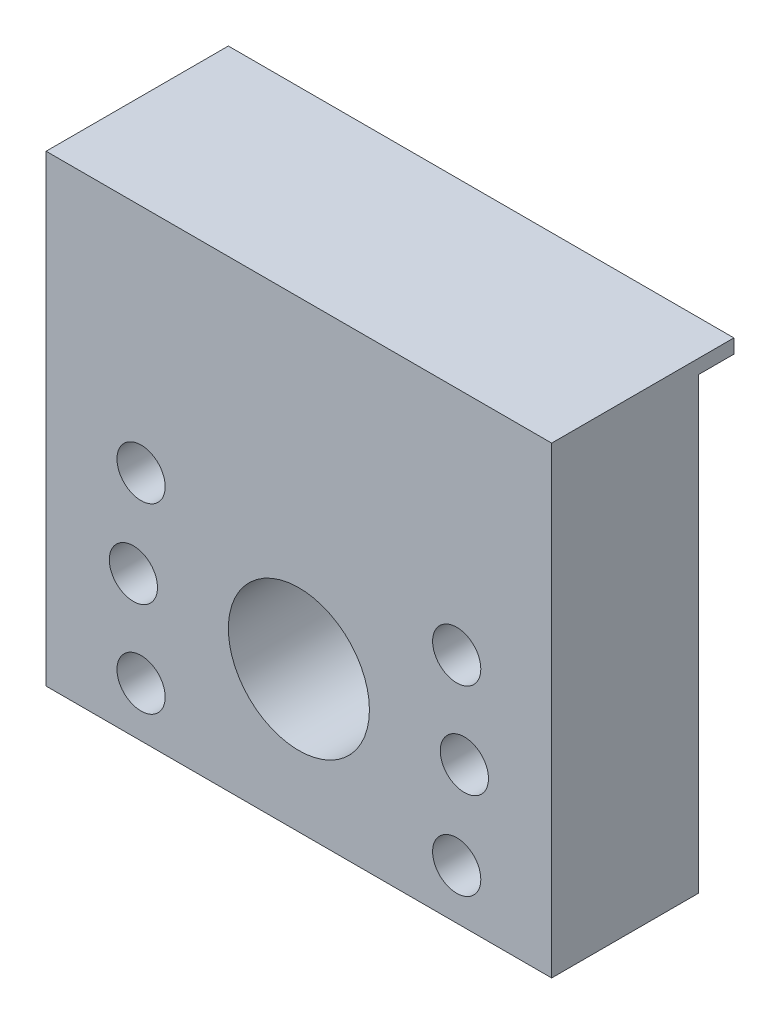
from build123d import *

# Parameters (mm, degrees)
SKETCH1_W             = 43
SKETCH1_H             = 48.1
SKETCH1_R             = 2.05
SKETCH1_R_2           = 6
BOSS_EXTRUDE1_DEPTH   = 12.5
SKETCH1_3_W           = 43
SKETCH1_3_H           = 10
BOSS_EXTRUDE2_DEPTH   = 3
MOVE_FACE1_BY         = 0.1
CROQUIS1_W            = 43
CROQUIS1_H            = 8.7
CORTAR_EXTRUIR1_DEPTH = 230.388992761
CROQUIS2_R            = 1.6
PINES_PRE_SERIE_DEPTH = 3
CROQUIS3_R            = 2.05
CORTAR_EXTRUIR2_DEPTH = 230.205824533


with BuildPart() as part:
    # Sketch1 → Boss-Extrude1 (new body)
    with BuildSketch(Plane.XY):
        with Locations((204, -15.05)):
            Rectangle(SKETCH1_W, SKETCH1_H)
        with Locations((217.423393759, -19.35)):
            Circle(SKETCH1_R, mode=Mode.SUBTRACT)
        with Locations((190.576606241, -34.85)):
            Circle(SKETCH1_R, mode=Mode.SUBTRACT)
        with Locations((217.423393759, -34.85)):
            Circle(SKETCH1_R, mode=Mode.SUBTRACT)
        with Locations((190.576606241, -19.35)):
            Circle(SKETCH1_R, mode=Mode.SUBTRACT)
        with Locations((204, -27.1)):
            Circle(SKETCH1_R_2, mode=Mode.SUBTRACT)
    extrude(amount=BOSS_EXTRUDE1_DEPTH)

    # Sketch1_3 → Boss-Extrude2 (add)
    with BuildSketch(Plane.XY):
        with Locations((204, 4)):
            Rectangle(SKETCH1_3_W, SKETCH1_3_H)
    extrude(amount=-BOSS_EXTRUDE2_DEPTH)

    # Move Face1: a face moved inward by 0.1
    extrude(part.faces().sort_by_distance((204, -1, -1.5))[0], amount=MOVE_FACE1_BY, dir=(0, 1, 0), mode=Mode.SUBTRACT)

    # Croquis1 → Cortar-Extruir1 (cut, through all)
    with BuildSketch(Plane(origin=(0, 0, -3), x_dir=(-1, 0, 0), z_dir=(0, 0, -1))):
        with Locations((-204, 4.65)):
            Rectangle(CROQUIS1_W, CROQUIS1_H)
    extrude(amount=-CORTAR_EXTRUIR1_DEPTH, mode=Mode.SUBTRACT)

    # Croquis2 → Pines Pre-serie (add)
    with BuildSketch(Plane(origin=(0, 0, 0), x_dir=(-1, 0, 0), z_dir=(0, 0, -1))):
        with Locations(Location((-210.9715045, -32.275, 0), (0, 0, 180))):
            Circle(CROQUIS2_R)
        with Locations(Location((-197.0284955, -32.275, 0), (0, 0, 180))):
            Circle(CROQUIS2_R)
    extrude(amount=PINES_PRE_SERIE_DEPTH)

    # Croquis3 → Cortar-Extruir2 (cut, through all)
    with BuildSketch(Plane(origin=(0, 0, 0), x_dir=(-1, 0, 0), z_dir=(0, 0, -1))):
        with Locations((-218.075, -27.1)):
            Circle(CROQUIS3_R)
        with Locations((-189.925, -27.1)):
            Circle(CROQUIS3_R)
    extrude(amount=-CORTAR_EXTRUIR2_DEPTH, mode=Mode.SUBTRACT)


solid = part.part
